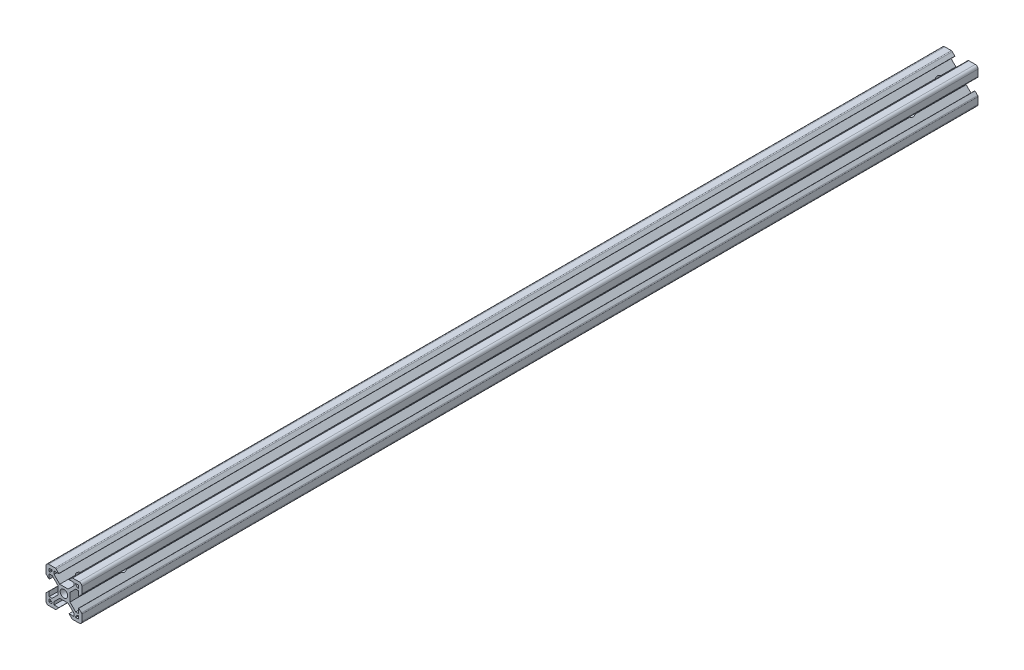
from build123d import *

# Parameters (mm, degrees)
SKETCH6_R           = 2.1
BOSS_EXTRUDE1_DEPTH = 500
SKETCH7_R           = 2.75
CUT_EXTRUDE1_DEPTH  = 11
SKETCH8_R           = 2.75
CUT_EXTRUDE2_DEPTH  = 11


with BuildPart() as part:
    # Sketch6 → Boss-Extrude1 (new body)
    with BuildSketch(Plane.XY):
        with BuildLine():
            Line((-3.4, -2.339339828), (-3.4, 2.339339828))
            Line((-3.4, 2.339339828), (-6.560660172, 5.5))
            Line((-6.560660172, 5.5), (-8.2, 5.5))
            Line((-8.2, 5.5), (-8.2, 2.89))
            Line((-8.2, 2.89), (-8.31, 2.89))
            Line((-8.31, 2.89), (-9.768614357, 4.348614357))
            ThreePointArc((-9.768614357, 4.348614357), (-9.939864831, 4.604908803), (-10, 4.907228714))
            Line((-10, 4.907228714), (-10, 8.5))
            ThreePointArc((-10, 8.5), (-9.560660172, 9.560660172), (-8.5, 10))
            Line((-8.5, 10), (-4.907228714, 10))
            ThreePointArc((-4.907228714, 10), (-4.604908803, 9.939864831), (-4.348614357, 9.768614357))
            Line((-4.348614357, 9.768614357), (-2.89, 8.31))
            Line((-2.89, 8.31), (-2.89, 8.2))
            Line((-2.89, 8.2), (-5.5, 8.2))
            Line((-5.5, 8.2), (-5.5, 6.560660172))
            Line((-5.5, 6.560660172), (-2.339339828, 3.4))
            Line((-2.339339828, 3.4), (2.339339828, 3.4))
            Line((2.339339828, 3.4), (5.5, 6.560660172))
            Line((5.5, 6.560660172), (5.5, 8.2))
            Line((5.5, 8.2), (2.89, 8.2))
            Line((2.89, 8.2), (2.89, 8.31))
            Line((2.89, 8.31), (4.348614357, 9.768614357))
            ThreePointArc((4.348614357, 9.768614357), (4.604908803, 9.939864831), (4.907228714, 10))
            Line((4.907228714, 10), (8.5, 10))
            ThreePointArc((8.5, 10), (9.560660172, 9.560660172), (10, 8.5))
            Line((10, 8.5), (10, 4.907228714))
            ThreePointArc((10, 4.907228714), (9.939864831, 4.604908803), (9.768614357, 4.348614357))
            Line((9.768614357, 4.348614357), (8.31, 2.89))
            Line((8.31, 2.89), (8.2, 2.89))
            Line((8.2, 2.89), (8.2, 5.5))
            Line((8.2, 5.5), (6.560660172, 5.5))
            Line((6.560660172, 5.5), (3.4, 2.339339828))
            Line((3.4, 2.339339828), (3.4, -2.339339828))
            Line((3.4, -2.339339828), (6.560660172, -5.5))
            Line((6.560660172, -5.5), (8.2, -5.5))
            Line((8.2, -5.5), (8.2, -2.89))
            Line((8.2, -2.89), (8.31, -2.89))
            Line((8.31, -2.89), (9.768614357, -4.348614357))
            ThreePointArc((9.768614357, -4.348614357), (9.939864831, -4.604908803), (10, -4.907228714))
            Line((10, -4.907228714), (10, -8.5))
            ThreePointArc((10, -8.5), (9.560660172, -9.560660172), (8.5, -10))
            Line((8.5, -10), (4.907228714, -10))
            ThreePointArc((4.907228714, -10), (4.604908803, -9.939864831), (4.348614357, -9.768614357))
            Line((4.348614357, -9.768614357), (2.89, -8.31))
            Line((2.89, -8.31), (2.89, -8.2))
            Line((2.89, -8.2), (5.5, -8.2))
            Line((5.5, -8.2), (5.5, -6.560660172))
            Line((5.5, -6.560660172), (2.339339828, -3.4))
            Line((2.339339828, -3.4), (-2.339339828, -3.4))
            Line((-2.339339828, -3.4), (-5.5, -6.560660172))
            Line((-5.5, -6.560660172), (-5.5, -8.2))
            Line((-5.5, -8.2), (-2.89, -8.2))
            Line((-2.89, -8.2), (-2.89, -8.31))
            Line((-2.89, -8.31), (-4.348614357, -9.768614357))
            ThreePointArc((-4.348614357, -9.768614357), (-4.604908803, -9.939864831), (-4.907228714, -10))
            Line((-4.907228714, -10), (-8.5, -10))
            ThreePointArc((-8.5, -10), (-9.560660172, -9.560660172), (-10, -8.5))
            Line((-10, -8.5), (-10, -4.907228714))
            ThreePointArc((-10, -4.907228714), (-9.939864831, -4.604908803), (-9.768614357, -4.348614357))
            Line((-9.768614357, -4.348614357), (-8.31, -2.89))
            Line((-8.31, -2.89), (-8.2, -2.89))
            Line((-8.2, -2.89), (-8.2, -5.5))
            Line((-8.2, -5.5), (-6.560660172, -5.5))
            Line((-6.560660172, -5.5), (-3.4, -2.339339828))
        make_face()
        Circle(SKETCH6_R, mode=Mode.SUBTRACT)
        Polygon((-7.66, 6.57), (-6.57, 7.66), (-6.57, 8.2), (-8.2, 8.2), (-8.2, 6.57), align=None, mode=Mode.SUBTRACT)
        Polygon((8.2, 6.57), (7.66, 6.57), (6.57, 7.66), (6.57, 8.2), (8.2, 8.2), align=None, mode=Mode.SUBTRACT)
        Polygon((7.66, -6.57), (6.57, -7.66), (6.57, -8.2), (8.2, -8.2), (8.2, -6.57), align=None, mode=Mode.SUBTRACT)
        Polygon((-8.2, -6.57), (-7.66, -6.57), (-6.57, -7.66), (-6.57, -8.2), (-8.2, -8.2), align=None, mode=Mode.SUBTRACT)
    extrude(amount=-BOSS_EXTRUDE1_DEPTH)

    # Sketch7 → Cut-Extrude1 (cut, symmetric)
    with BuildSketch(Plane(origin=(0, 0, 0), x_dir=(1, 0, 0), z_dir=(0, 1, 0))):
        with Locations((0, 490)):
            Circle(SKETCH7_R)
    cut_extrude1 = extrude(amount=CUT_EXTRUDE1_DEPTH, both=True, mode=Mode.SUBTRACT)

    # Sketch8 → Cut-Extrude2 (cut, symmetric)
    with BuildSketch(Plane(origin=(0, 0, 0), x_dir=(0, 0, -1), z_dir=(1, 0, 0))):
        with Locations((470, 0)):
            Circle(SKETCH8_R)
    cut_extrude2 = extrude(amount=CUT_EXTRUDE2_DEPTH, both=True, mode=Mode.SUBTRACT)

    # Mirror1: Cut-Extrude1, Cut-Extrude2 across plane
    add(cut_extrude1.mirror(Plane.XY.offset(-250)), mode=Mode.SUBTRACT)
    add(cut_extrude2.mirror(Plane.XY.offset(-250)), mode=Mode.SUBTRACT)


solid = part.part
